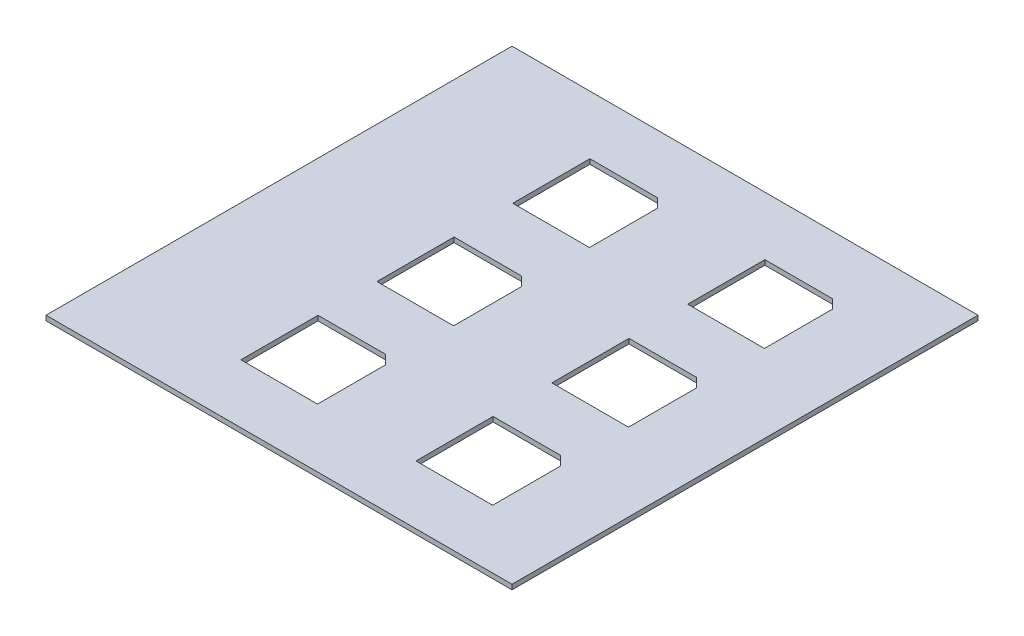
from build123d import *

# Parameters (mm, degrees)
SKETCH1_W           = 304.8
SKETCH1_H           = 304.8
BOSS_EXTRUDE1_DEPTH = 3.175


with BuildPart() as part:
    # Sketch1 → Boss-Extrude1 (new body)
    with BuildSketch(Plane(origin=(0, 0, 0), x_dir=(1, 0, 0), z_dir=(0, 1, 0))):
        with Locations((-12.540052417, 0)):
            Rectangle(SKETCH1_W, SKETCH1_H)
        Polygon((-75.698500695, 63.659947583), (-25.559947583, 63.659947583), (-25.559947583, 108.120227238), (-31.557978093, 114.118257748), (-75.698500695, 114.118257748), align=None, mode=Mode.SUBTRACT)
        Polygon((38.701669621, 63.703874457), (88.840222733, 63.703874457), (88.840222733, 108.164154112), (82.842192224, 114.162184621), (38.701669621, 114.162184621), align=None, mode=Mode.SUBTRACT)
        Polygon((-75.76813518, -25.114152208), (-25.629582068, -25.114152208), (-25.629582068, 19.346127447), (-31.627612577, 25.344157957), (-75.76813518, 25.344157957), align=None, mode=Mode.SUBTRACT)
        Polygon((38.837246674, -25.31385175), (88.975799786, -25.31385175), (88.975799786, 19.146427905), (82.977769277, 25.144458414), (38.837246674, 25.144458414), align=None, mode=Mode.SUBTRACT)
        Polygon((38.618131254, -113.973933449), (88.756684366, -113.973933449), (88.756684366, -69.513653793), (82.758653857, -63.515623284), (38.618131254, -63.515623284), align=None, mode=Mode.SUBTRACT)
        Polygon((-75.926077633, -113.955197726), (-25.787524521, -113.955197726), (-25.787524521, -69.494918071), (-31.78555503, -63.496887561), (-75.926077633, -63.496887561), align=None, mode=Mode.SUBTRACT)
    extrude(amount=BOSS_EXTRUDE1_DEPTH)


solid = part.part
